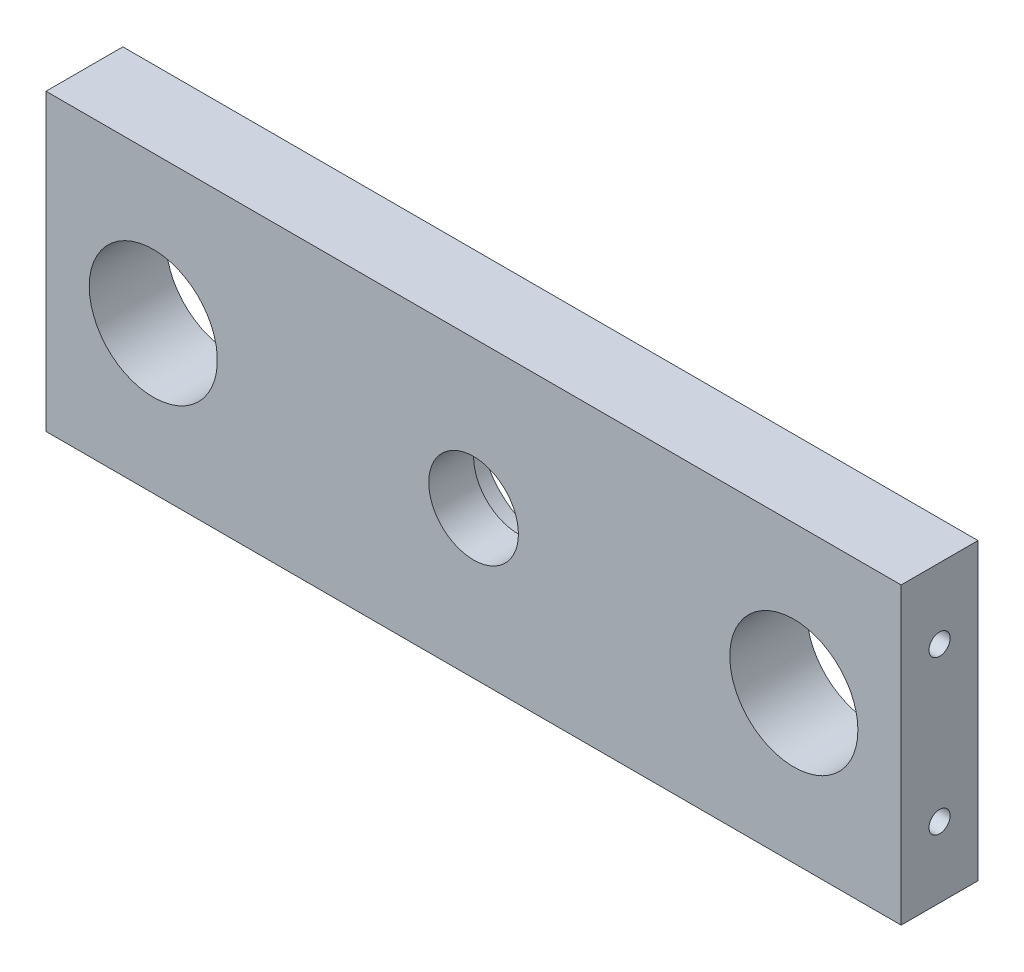
from build123d import *

# Parameters (mm, degrees)
SKETCH1_W           = 133.5
SKETCH1_H           = 46
SKETCH1_R           = 10
SKETCH1_R_2         = 7
BOSS_EXTRUDE1_DEPTH = 12
SKETCH2_R           = 11
CUT_EXTRUDE1_DEPTH  = 5
M4_TAPPED_HOLE1_D   = 3.3


with BuildPart() as part:
    # Sketch1 → Boss-Extrude1 (new body)
    with BuildSketch(Plane.XY):
        Rectangle(SKETCH1_W, SKETCH1_H)
        with Locations((50, 0)):
            Circle(SKETCH1_R, mode=Mode.SUBTRACT)
        with Locations((-50, 0)):
            Circle(SKETCH1_R, mode=Mode.SUBTRACT)
        Circle(SKETCH1_R_2, mode=Mode.SUBTRACT)
    extrude(amount=BOSS_EXTRUDE1_DEPTH)

    # Sketch2 → Cut-Extrude1 (cut)
    with BuildSketch(Plane(origin=(0, 0, 0), x_dir=(-1, 0, 0), z_dir=(0, 0, -1))):
        Circle(SKETCH2_R)
    extrude(amount=-CUT_EXTRUDE1_DEPTH, mode=Mode.SUBTRACT)

    # M4 Tapped Hole1 (through all)
    with Locations(Plane.ZY.offset(66.75)):
        with Locations((6, 12), (6, -12)):
            m4_tapped_hole1 = Hole(M4_TAPPED_HOLE1_D / 2)

    # Mirror1: M4 Tapped Hole1 across plane
    add(m4_tapped_hole1.mirror(Plane(origin=(0, 0, 0), x_dir=(0, 0, 1), z_dir=(1, 0, 0))), mode=Mode.SUBTRACT)


solid = part.part
